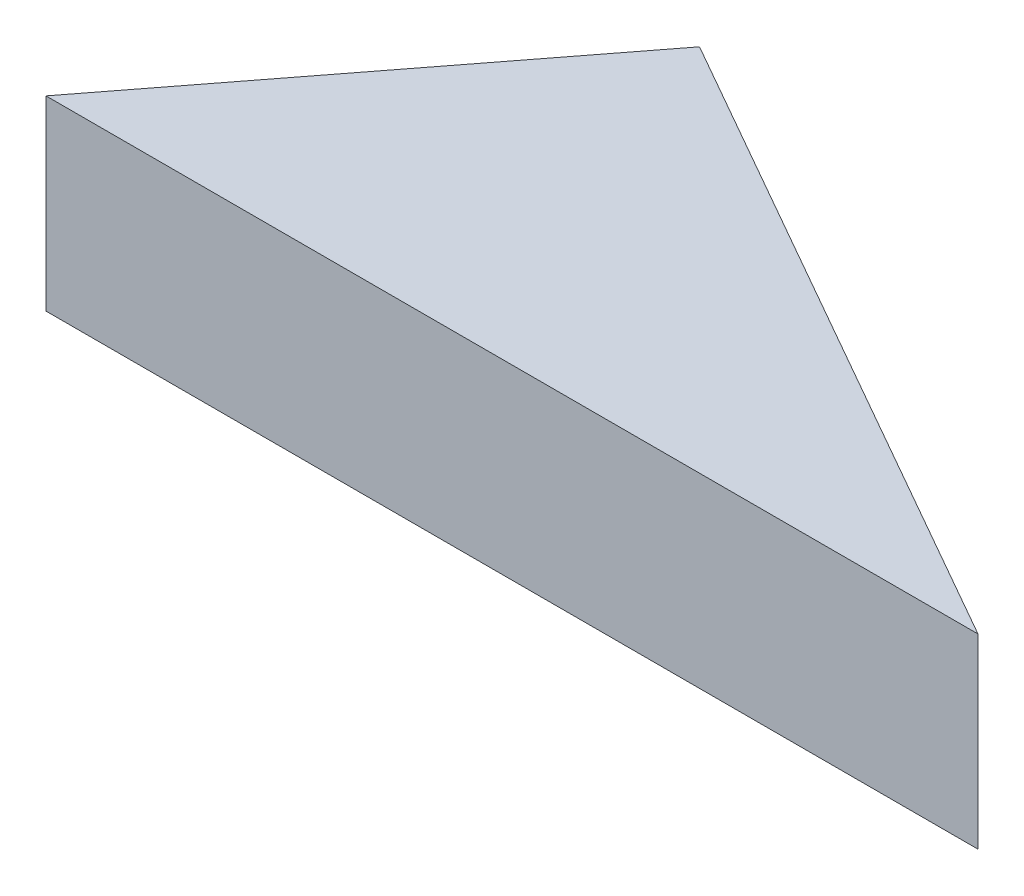
from build123d import *

# Parameters (mm, degrees)
BOSS_EXTRUDE1_DEPTH = 1


with BuildPart() as part:
    # Sketch1 → Boss-Extrude1 (new body)
    with BuildSketch(Plane(origin=(0, 0, 0), x_dir=(1, 0, 0), z_dir=(0, 1, 0))):
        Polygon((0, 0), (5, 0), (1.525, 1.981003534), align=None)
    extrude(amount=BOSS_EXTRUDE1_DEPTH)


solid = part.part
